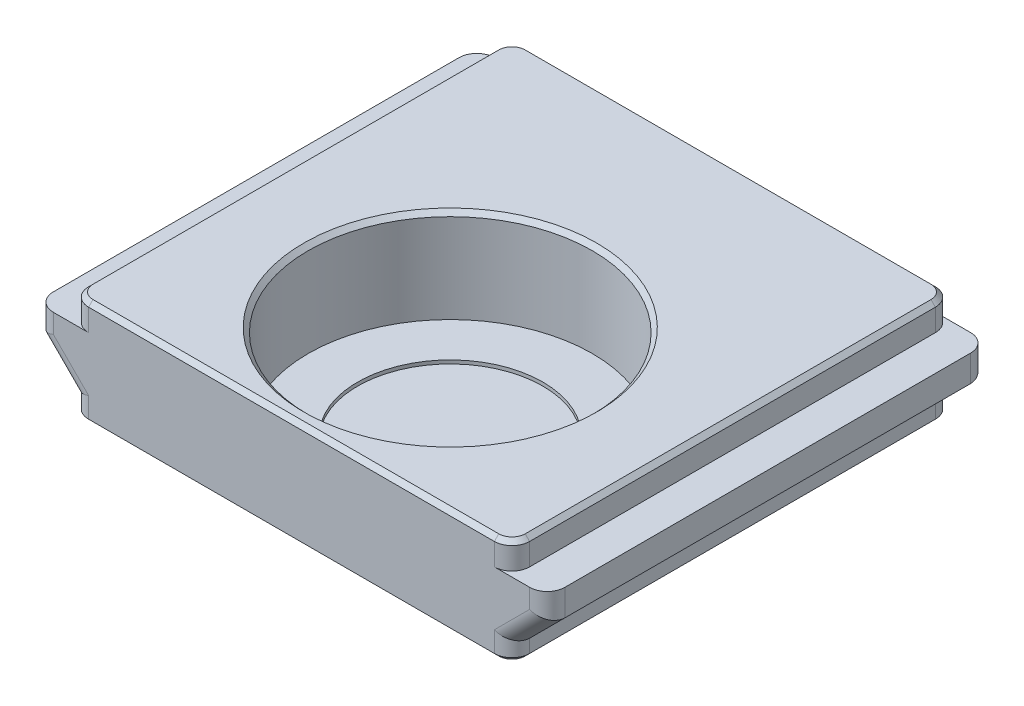
from build123d import *

# Parameters (mm, degrees)
SKETCH1_W           = 25
SKETCH1_H           = 25
BOSS_EXTRUDE1_DEPTH = 6
SKETCH2_R           = 8.05
CUT_EXTRUDE1_DEPTH  = 5.5
BOSS_EXTRUDE2_DEPTH = 25
SKETCH5_R           = 2.2
CUT_EXTRUDE3_DEPTH  = 7.5
SKETCH6_R           = 8.05
SKETCH6_R_2         = 5.25
BOSS_EXTRUDE3_DEPTH = 0.2
FILLET1_R           = 1
CHAMFER1_SIZE       = 0.5
CHAMFER2_SIZE       = 0.25


with BuildPart() as part:
    # Sketch1 → Boss-Extrude1 (new body)
    with BuildSketch(Plane(origin=(0, 0, 0), x_dir=(1, 0, 0), z_dir=(0, 1, 0))):
        Rectangle(SKETCH1_W, SKETCH1_H)
    extrude(amount=BOSS_EXTRUDE1_DEPTH)

    # Sketch2 → Cut-Extrude1 (cut)
    with BuildSketch(Plane(origin=(0, 6, 0), x_dir=(1, 0, 0), z_dir=(0, 1, 0))):
        with Locations((0, -3.5)):
            Circle(SKETCH2_R)
    extrude(amount=-CUT_EXTRUDE1_DEPTH, mode=Mode.SUBTRACT)

    # Sketch4 → Boss-Extrude2 (add)
    with BuildSketch(Plane.XY.offset(12.5)):
        Polygon((12.5, 4.5), (14.5, 4.5), (14.5, 3), (12.5, 1), align=None)
        Polygon((-12.5, 1), (-12.5, 4.5), (-14.5, 4.5), (-14.5, 3), align=None)
    extrude(amount=-BOSS_EXTRUDE2_DEPTH)

    # Sketch5 → Cut-Extrude3 (cut)
    with BuildSketch(Plane(origin=(0, 0, -12.5), x_dir=(-1, 0, 0), z_dir=(0, 0, -1))):
        with Locations((0, 3)):
            Circle(SKETCH5_R)
    extrude(amount=-CUT_EXTRUDE3_DEPTH, mode=Mode.SUBTRACT)

    # Sketch6 → Boss-Extrude3 (add)
    with BuildSketch(Plane(origin=(0, 0.5, 0), x_dir=(1, 0, 0), z_dir=(0, 1, 0))):
        with Locations((0, -3.5)):
            Circle(SKETCH6_R)
        with Locations((0, -3.5)):
            Circle(SKETCH6_R_2, mode=Mode.SUBTRACT)
    extrude(amount=BOSS_EXTRUDE3_DEPTH)

    # Fillet1
    fillet1_edges = [part.edges().sort_by_distance(p)[0] for p in [
        (12.5, 0.5, -12.5),
        (12.5, 0.5, 12.5),
        (13.5, 2, 12.5),
        (14.5, 3.75, 12.5),
        (14.5, 3.75, -12.5),
        (13.5, 2, -12.5),
        (-12.5, 0.5, 12.5),
        (-12.5, 0.5, -12.5),
        (-13.5, 2, 12.5),
        (-14.5, 3.75, 12.5),
        (-13.5, 2, -12.5),
        (-14.5, 3.75, -12.5),
        (12.5, 5.25, 12.5),
        (-12.5, 5.25, 12.5),
        (-12.5, 5.25, -12.5),
        (12.5, 5.25, -12.5),
    ]]
    fillet(fillet1_edges, radius=FILLET1_R)

    # Chamfer1
    chamfer1_edges = [part.edges().sort_by_distance(p)[0] for p in [
        (2.2, 3, -12.5),
    ]]
    chamfer(chamfer1_edges, length=CHAMFER1_SIZE)

    # Chamfer2
    chamfer2_edges = [part.edges().sort_by_distance(p)[0] for p in [
        (-8.05, 6, 3.5),
        (0, 0, 12.5),
        (0, 6, 12.5),
        (0, 0, -12.5),
        (0, 6, -12.5),
        (12.5, 0, 0),
        (-12.5, 0, 0),
        (12.207106781, 0, -12.207106781),
        (-12.207106781, 0, -12.207106781),
        (-12.207106781, 0, 12.207106781),
        (12.207106781, 0, 12.207106781),
        (12.5, 6, 0),
        (-12.5, 6, 0),
        (12.207106781, 6, -12.207106781),
        (-12.207106781, 6, -12.207106781),
        (-12.207106781, 6, 12.207106781),
        (12.207106781, 6, 12.207106781),
    ]]
    chamfer(chamfer2_edges, length=CHAMFER2_SIZE)


solid = part.part
